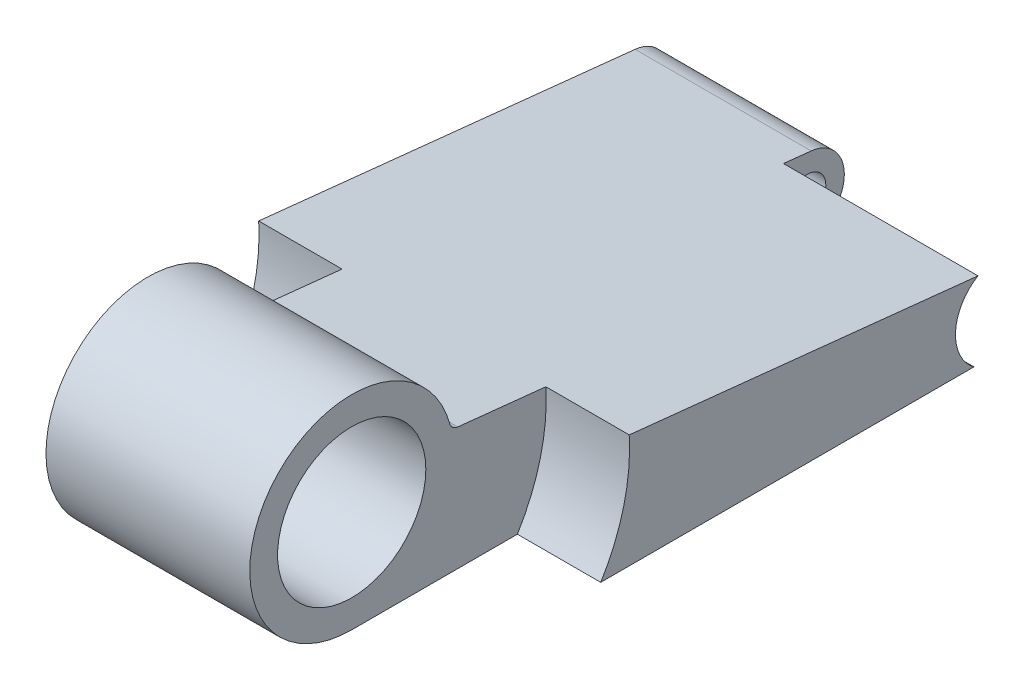
from build123d import *

# Parameters (mm, degrees)
SKETCH1_R           = 3.1369
SKETCH1_R_2         = 0.78486
BOSS_EXTRUDE1_DEPTH = 15.68196
FILLET1_R           = 0.39116
SKETCH2_R           = 8.23214
CUT_EXTRUDE1_DEPTH  = 3.52806
SKETCH3_R           = 8.23214
CUT_EXTRUDE2_DEPTH  = 3.52806
SKETCH4_R           = 1.96088
CUT_EXTRUDE3_DEPTH  = 8.23214


with BuildPart() as part:
    # Sketch1 → Boss-Extrude1 (new body)
    with BuildSketch(Plane(origin=(0, 0, 0), x_dir=(0, 0, -1), z_dir=(1, 0, 0))):
        with BuildLine():
            Line((-6.102081164, -4.312920003), (17.882851381, -4.312920003))
            ThreePointArc((17.882851381, -4.312920003), (19.449151228, -2.826510031), (18.046700375, -1.184608261))
            Line((18.046700375, -1.184608261), (-1.886270539, 0.910065763))
            ThreePointArc((-1.886270539, 0.910065763), (-9.458144317, 2.708896275), (-6.102081164, -4.312920003))
        make_face()
        with Locations((-6.102081164, -3e-09)):
            Circle(SKETCH1_R, mode=Mode.SUBTRACT)
        with Locations((17.882851381, -2.74447324)):
            Circle(SKETCH1_R_2, mode=Mode.SUBTRACT)
    extrude(amount=-BOSS_EXTRUDE1_DEPTH)

    # Fillet1
    fillet1_edges = [part.edges().sort_by_distance(p)[0] for p in [
        (-7.84098, 0.910065763, 1.886270539),
    ]]
    fillet(fillet1_edges, radius=FILLET1_R)

    # Sketch2 → Cut-Extrude1 (cut)
    with BuildSketch(Plane(origin=(0, 0, 0), x_dir=(0, 0, -1), z_dir=(1, 0, 0))):
        with Locations((-6.102081164, -3e-09)):
            Circle(SKETCH2_R)
    extrude(amount=-CUT_EXTRUDE1_DEPTH, mode=Mode.SUBTRACT)

    # Sketch3 → Cut-Extrude2 (cut)
    with BuildSketch(Plane.ZY.offset(15.68196)):
        with Locations((6.102081164, -3e-09)):
            Circle(SKETCH3_R)
    extrude(amount=-CUT_EXTRUDE2_DEPTH, mode=Mode.SUBTRACT)

    # Sketch4 → Cut-Extrude3 (cut)
    with BuildSketch(Plane(origin=(0, 0, 0), x_dir=(0, 0, -1), z_dir=(1, 0, 0))):
        with Locations((17.882851381, -2.74447324)):
            Circle(SKETCH4_R)
    extrude(amount=-CUT_EXTRUDE3_DEPTH, mode=Mode.SUBTRACT)


solid = part.part
